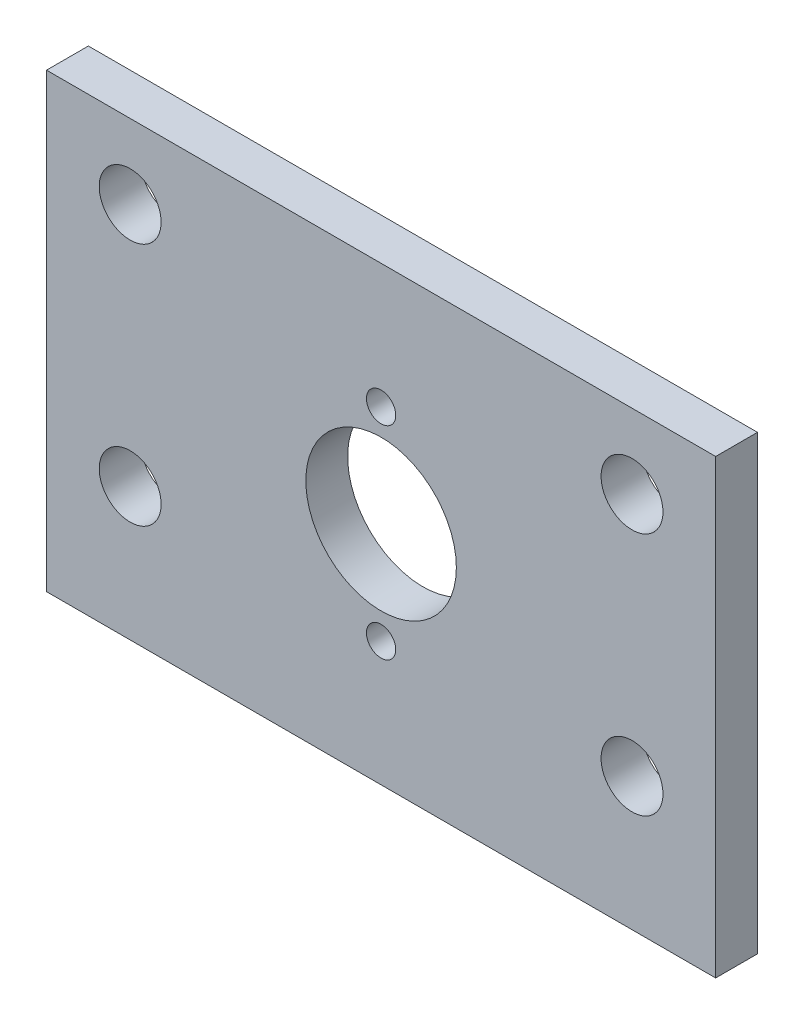
from build123d import *

# Parameters (mm, degrees)
SKETCH1_W           = 50.8
SKETCH1_H           = 34.29
SKETCH1_R           = 2.3495
SKETCH1_R_2         = 1.11125
SKETCH1_R_3         = 5.715
BOSS_EXTRUDE1_DEPTH = 3.175


with BuildPart() as part:
    # Sketch1 → Boss-Extrude1 (new body)
    with BuildSketch(Plane.XY):
        Rectangle(SKETCH1_W, SKETCH1_H)
        with Locations((19.05, -7.0485)):
            Circle(SKETCH1_R, mode=Mode.SUBTRACT)
        with Locations((19.05, 11.4935)):
            Circle(SKETCH1_R, mode=Mode.SUBTRACT)
        with Locations((-19.05, 11.4935)):
            Circle(SKETCH1_R, mode=Mode.SUBTRACT)
        with Locations((-19.05, -7.0485)):
            Circle(SKETCH1_R, mode=Mode.SUBTRACT)
        with Locations((0, 7.70255)):
            Circle(SKETCH1_R_2, mode=Mode.SUBTRACT)
        with Locations((0, -7.70255)):
            Circle(SKETCH1_R_2, mode=Mode.SUBTRACT)
        Circle(SKETCH1_R_3, mode=Mode.SUBTRACT)
    extrude(amount=BOSS_EXTRUDE1_DEPTH)


solid = part.part
